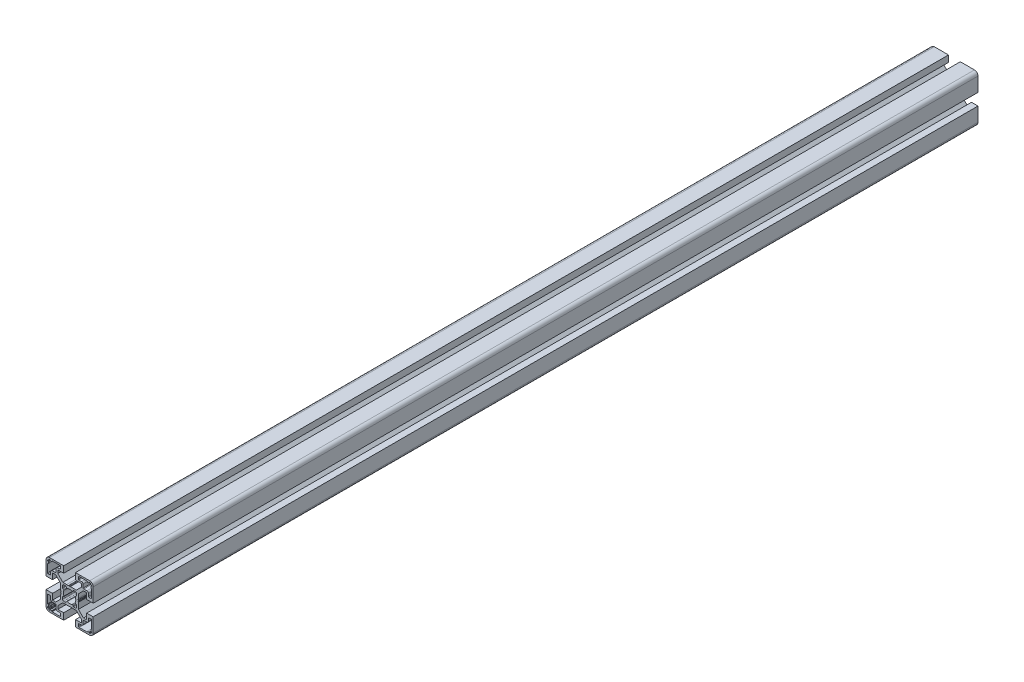
from build123d import *

# Parameters (mm, degrees)
BOSS_EXTRUDE1_DEPTH = 750


with BuildPart() as part:
    # Sketch1 → Boss-Extrude1 (new body)
    with BuildSketch(Plane.XY):
        with BuildLine():
            Line((-11.767766953, -10), (-14.5, -10))
            Line((-14.5, -10), (-14.5, -5))
            Line((-14.5, -5), (-20, -5))
            Line((-20, -5), (-20, -17))
            ThreePointArc((-20, -17), (-19.121320344, -19.121320344), (-17, -20))
            Line((-17, -20), (-5, -20))
            Line((-5, -20), (-5, -14.5))
            Line((-5, -14.5), (-10, -14.5))
            Line((-10, -14.5), (-10, -11.767766953))
            Line((-10, -11.767766953), (-5.732233047, -7.5))
            Line((-5.732233047, -7.5), (-0.653589838, -7.5))
            ThreePointArc((-0.653589838, -7.5), (-0.524180316, -7.482962913), (-0.403589838, -7.433012702))
            Line((-0.403589838, -7.433012702), (0, -7.2))
            Line((0, -7.2), (0.403589838, -7.433012702))
            ThreePointArc((0.403589838, -7.433012702), (0.653589838, -7.5), (0.903589838, -7.433012702))
            Line((0.903589838, -7.433012702), (1.218885629, -7.250976592))
            Line((1.218885629, -7.250976592), (2.5, -7.5))
            Line((2.5, -7.5), (5.732233047, -7.5))
            Line((5.732233047, -7.5), (10, -11.767766953))
            Line((10, -11.767766953), (10, -14.5))
            Line((10, -14.5), (5, -14.5))
            Line((5, -14.5), (5, -20))
            Line((5, -20), (17, -20))
            ThreePointArc((17, -20), (19.121320344, -19.121320344), (20, -17))
            Line((20, -17), (20, -5))
            Line((20, -5), (14.5, -5))
            Line((14.5, -5), (14.5, -10))
            Line((14.5, -10), (11.767766953, -10))
            Line((11.767766953, -10), (7.5, -5.732233047))
            Line((7.5, -5.732233047), (7.5, -0.653589838))
            ThreePointArc((7.5, -0.653589838), (7.482962913, -0.524180316), (7.433012702, -0.403589838))
            Line((7.433012702, -0.403589838), (7.2, 0))
            Line((7.2, 0), (7.433012702, 0.403589838))
            ThreePointArc((7.433012702, 0.403589838), (7.5, 0.653589838), (7.433012702, 0.903589838))
            Line((7.433012702, 0.903589838), (7.250976592, 1.218885629))
            Line((7.250976592, 1.218885629), (7.5, 2.5))
            Line((7.5, 2.5), (7.5, 5.732233047))
            Line((7.5, 5.732233047), (11.767766953, 10))
            Line((11.767766953, 10), (14.5, 10))
            Line((14.5, 10), (14.5, 5))
            Line((14.5, 5), (20, 5))
            Line((20, 5), (20, 17))
            ThreePointArc((20, 17), (19.121320344, 19.121320344), (17, 20))
            Line((17, 20), (5, 20))
            Line((5, 20), (5, 14.5))
            Line((5, 14.5), (10, 14.5))
            Line((10, 14.5), (10, 11.767766953))
            Line((10, 11.767766953), (5.732233047, 7.5))
            Line((5.732233047, 7.5), (0.653589838, 7.5))
            ThreePointArc((0.653589838, 7.5), (0.524180316, 7.482962913), (0.403589838, 7.433012702))
            Line((0.403589838, 7.433012702), (0, 7.2))
            Line((0, 7.2), (-0.403589838, 7.433012702))
            ThreePointArc((-0.403589838, 7.433012702), (-0.653589838, 7.5), (-0.903589838, 7.433012702))
            Line((-0.903589838, 7.433012702), (-1.218885629, 7.250976592))
            Line((-1.218885629, 7.250976592), (-2.5, 7.5))
            Line((-2.5, 7.5), (-5.732233047, 7.5))
            Line((-5.732233047, 7.5), (-10, 11.767766953))
            Line((-10, 11.767766953), (-10, 14.5))
            Line((-10, 14.5), (-5, 14.5))
            Line((-5, 14.5), (-5, 20))
            Line((-5, 20), (-17, 20))
            ThreePointArc((-17, 20), (-19.121320344, 19.121320344), (-20, 17))
            Line((-20, 17), (-20, 5))
            Line((-20, 5), (-14.5, 5))
            Line((-14.5, 5), (-14.5, 10))
            Line((-14.5, 10), (-11.767766953, 10))
            Line((-11.767766953, 10), (-7.5, 5.732233047))
            Line((-7.5, 5.732233047), (-7.5, 0.653589838))
            ThreePointArc((-7.5, 0.653589838), (-7.482962913, 0.524180316), (-7.433012702, 0.403589838))
            Line((-7.433012702, 0.403589838), (-7.2, 0))
            Line((-7.2, 0), (-7.433012702, -0.403589838))
            ThreePointArc((-7.433012702, -0.403589838), (-7.5, -0.653589838), (-7.433012702, -0.903589838))
            Line((-7.433012702, -0.903589838), (-7.250976592, -1.218885629))
            Line((-7.250976592, -1.218885629), (-7.5, -2.5))
            Line((-7.5, -2.5), (-7.5, -5.732233047))
            Line((-7.5, -5.732233047), (-11.767766953, -10))
        make_face()
        with BuildLine():
            Line((7.5, 16.5), (7.5, 18.2))
            ThreePointArc((7.5, 18.2), (7.646446609, 18.553553391), (8, 18.7))
            Line((8, 18.7), (14.8, 18.7))
            ThreePointArc((14.8, 18.7), (14.941421356, 18.641421356), (15, 18.5))
            Line((15, 18.5), (15, 18.2))
            ThreePointArc((15, 18.2), (15.058578644, 18.058578644), (15.2, 18))
            Line((15.2, 18), (16.4, 18))
            ThreePointArc((16.4, 18), (16.541421356, 18.058578644), (16.6, 18.2))
            Line((16.6, 18.2), (16.6, 18.5))
            ThreePointArc((16.6, 18.5), (16.658578644, 18.641421356), (16.8, 18.7))
            Line((16.8, 18.7), (17.3, 18.7))
            ThreePointArc((17.3, 18.7), (17.512132034, 18.612132034), (17.6, 18.4))
            Line((17.6, 18.4), (17.6, 17.9))
            ThreePointArc((17.6, 17.9), (17.687867966, 17.687867966), (17.9, 17.6))
            Line((17.9, 17.6), (18.4, 17.6))
            ThreePointArc((18.4, 17.6), (18.612132034, 17.512132034), (18.7, 17.3))
            Line((18.7, 17.3), (18.7, 16.8))
            ThreePointArc((18.7, 16.8), (18.641421356, 16.658578644), (18.5, 16.6))
            Line((18.5, 16.6), (18.2, 16.6))
            ThreePointArc((18.2, 16.6), (18.058578644, 16.541421356), (18, 16.4))
            Line((18, 16.4), (18, 15.2))
            ThreePointArc((18, 15.2), (18.058578644, 15.058578644), (18.2, 15))
            Line((18.2, 15), (18.5, 15))
            ThreePointArc((18.5, 15), (18.641421356, 14.941421356), (18.7, 14.8))
            Line((18.7, 14.8), (18.7, 8))
            ThreePointArc((18.7, 8), (18.553553391, 7.646446609), (18.2, 7.5))
            Line((18.2, 7.5), (16.5, 7.5))
            ThreePointArc((16.5, 7.5), (16.146446609, 7.646446609), (16, 8))
            Line((16, 8), (16, 10.2))
            ThreePointArc((16, 10.2), (15.619238816, 11.119238816), (14.7, 11.5))
            Line((14.7, 11.5), (12, 11.5))
            ThreePointArc((12, 11.5), (11.646446609, 11.646446609), (11.5, 12))
            Line((11.5, 12), (11.5, 14.7))
            ThreePointArc((11.5, 14.7), (11.119238816, 15.619238816), (10.2, 16))
            Line((10.2, 16), (8, 16))
            ThreePointArc((8, 16), (7.646446609, 16.146446609), (7.5, 16.5))
        make_face(mode=Mode.SUBTRACT)
        with BuildLine():
            Line((14.8, -18.7), (8, -18.7))
            ThreePointArc((8, -18.7), (7.646446609, -18.553553391), (7.5, -18.2))
            Line((7.5, -18.2), (7.5, -16.5))
            ThreePointArc((7.5, -16.5), (7.646446609, -16.146446609), (8, -16))
            Line((8, -16), (10.2, -16))
            ThreePointArc((10.2, -16), (11.119238816, -15.619238816), (11.5, -14.7))
            Line((11.5, -14.7), (11.5, -12))
            ThreePointArc((11.5, -12), (11.646446609, -11.646446609), (12, -11.5))
            Line((12, -11.5), (14.7, -11.5))
            ThreePointArc((14.7, -11.5), (15.619238816, -11.119238816), (16, -10.2))
            Line((16, -10.2), (16, -8))
            ThreePointArc((16, -8), (16.146446609, -7.646446609), (16.5, -7.5))
            Line((16.5, -7.5), (18.2, -7.5))
            ThreePointArc((18.2, -7.5), (18.553553391, -7.646446609), (18.7, -8))
            Line((18.7, -8), (18.7, -14.8))
            ThreePointArc((18.7, -14.8), (18.641421356, -14.941421356), (18.5, -15))
            Line((18.5, -15), (18.2, -15))
            ThreePointArc((18.2, -15), (18.058578644, -15.058578644), (18, -15.2))
            Line((18, -15.2), (18, -16.4))
            ThreePointArc((18, -16.4), (18.058578644, -16.541421356), (18.2, -16.6))
            Line((18.2, -16.6), (18.5, -16.6))
            ThreePointArc((18.5, -16.6), (18.641421356, -16.658578644), (18.7, -16.8))
            Line((18.7, -16.8), (18.7, -17.3))
            ThreePointArc((18.7, -17.3), (18.612132034, -17.512132034), (18.4, -17.6))
            Line((18.4, -17.6), (17.9, -17.6))
            ThreePointArc((17.9, -17.6), (17.687867966, -17.687867966), (17.6, -17.9))
            Line((17.6, -17.9), (17.6, -18.4))
            ThreePointArc((17.6, -18.4), (17.512132034, -18.612132034), (17.3, -18.7))
            Line((17.3, -18.7), (16.8, -18.7))
            ThreePointArc((16.8, -18.7), (16.658578644, -18.641421356), (16.6, -18.5))
            Line((16.6, -18.5), (16.6, -18.2))
            ThreePointArc((16.6, -18.2), (16.541421356, -18.058578644), (16.4, -18))
            Line((16.4, -18), (15.2, -18))
            ThreePointArc((15.2, -18), (15.058578644, -18.058578644), (15, -18.2))
            Line((15, -18.2), (15, -18.5))
            ThreePointArc((15, -18.5), (14.941421356, -18.641421356), (14.8, -18.7))
        make_face(mode=Mode.SUBTRACT)
        with BuildLine():
            Line((-18.7, 16.8), (-18.7, 17.3))
            ThreePointArc((-18.7, 17.3), (-18.612132034, 17.512132034), (-18.4, 17.6))
            Line((-18.4, 17.6), (-17.9, 17.6))
            ThreePointArc((-17.9, 17.6), (-17.687867966, 17.687867966), (-17.6, 17.9))
            Line((-17.6, 17.9), (-17.6, 18.4))
            ThreePointArc((-17.6, 18.4), (-17.512132034, 18.612132034), (-17.3, 18.7))
            Line((-17.3, 18.7), (-16.8, 18.7))
            ThreePointArc((-16.8, 18.7), (-16.658578644, 18.641421356), (-16.6, 18.5))
            Line((-16.6, 18.5), (-16.6, 18.2))
            ThreePointArc((-16.6, 18.2), (-16.541421356, 18.058578644), (-16.4, 18))
            Line((-16.4, 18), (-15.2, 18))
            ThreePointArc((-15.2, 18), (-15.058578644, 18.058578644), (-15, 18.2))
            Line((-15, 18.2), (-15, 18.5))
            ThreePointArc((-15, 18.5), (-14.941421356, 18.641421356), (-14.8, 18.7))
            Line((-14.8, 18.7), (-8, 18.7))
            ThreePointArc((-8, 18.7), (-7.646446609, 18.553553391), (-7.5, 18.2))
            Line((-7.5, 18.2), (-7.5, 16.5))
            ThreePointArc((-7.5, 16.5), (-7.646446609, 16.146446609), (-8, 16))
            Line((-8, 16), (-10.2, 16))
            ThreePointArc((-10.2, 16), (-11.119238816, 15.619238816), (-11.5, 14.7))
            Line((-11.5, 14.7), (-11.5, 12))
            ThreePointArc((-11.5, 12), (-11.646446609, 11.646446609), (-12, 11.5))
            Line((-12, 11.5), (-14.7, 11.5))
            ThreePointArc((-14.7, 11.5), (-15.619238816, 11.119238816), (-16, 10.2))
            Line((-16, 10.2), (-16, 8))
            ThreePointArc((-16, 8), (-16.146446609, 7.646446609), (-16.5, 7.5))
            Line((-16.5, 7.5), (-18.2, 7.5))
            ThreePointArc((-18.2, 7.5), (-18.553553391, 7.646446609), (-18.7, 8))
            Line((-18.7, 8), (-18.7, 14.8))
            ThreePointArc((-18.7, 14.8), (-18.641421356, 14.941421356), (-18.5, 15))
            Line((-18.5, 15), (-18.2, 15))
            ThreePointArc((-18.2, 15), (-18.058578644, 15.058578644), (-18, 15.2))
            Line((-18, 15.2), (-18, 16.4))
            ThreePointArc((-18, 16.4), (-18.058578644, 16.541421356), (-18.2, 16.6))
            Line((-18.2, 16.6), (-18.5, 16.6))
            ThreePointArc((-18.5, 16.6), (-18.641421356, 16.658578644), (-18.7, 16.8))
        make_face(mode=Mode.SUBTRACT)
        with BuildLine():
            Line((-18.7, -14.8), (-18.7, -8))
            ThreePointArc((-18.7, -8), (-18.553553391, -7.646446609), (-18.2, -7.5))
            Line((-18.2, -7.5), (-16.5, -7.5))
            ThreePointArc((-16.5, -7.5), (-16.146446609, -7.646446609), (-16, -8))
            Line((-16, -8), (-16, -10.2))
            ThreePointArc((-16, -10.2), (-15.619238816, -11.119238816), (-14.7, -11.5))
            Line((-14.7, -11.5), (-12, -11.5))
            ThreePointArc((-12, -11.5), (-11.646446609, -11.646446609), (-11.5, -12))
            Line((-11.5, -12), (-11.5, -14.7))
            ThreePointArc((-11.5, -14.7), (-11.119238816, -15.619238816), (-10.2, -16))
            Line((-10.2, -16), (-8, -16))
            ThreePointArc((-8, -16), (-7.646446609, -16.146446609), (-7.5, -16.5))
            Line((-7.5, -16.5), (-7.5, -18.2))
            ThreePointArc((-7.5, -18.2), (-7.646446609, -18.553553391), (-8, -18.7))
            Line((-8, -18.7), (-14.8, -18.7))
            ThreePointArc((-14.8, -18.7), (-14.941421356, -18.641421356), (-15, -18.5))
            Line((-15, -18.5), (-15, -18.2))
            ThreePointArc((-15, -18.2), (-15.058578644, -18.058578644), (-15.2, -18))
            Line((-15.2, -18), (-16.4, -18))
            ThreePointArc((-16.4, -18), (-16.541421356, -18.058578644), (-16.6, -18.2))
            Line((-16.6, -18.2), (-16.6, -18.5))
            ThreePointArc((-16.6, -18.5), (-16.658578644, -18.641421356), (-16.8, -18.7))
            Line((-16.8, -18.7), (-17.3, -18.7))
            ThreePointArc((-17.3, -18.7), (-17.512132034, -18.612132034), (-17.6, -18.4))
            Line((-17.6, -18.4), (-17.6, -17.9))
            ThreePointArc((-17.6, -17.9), (-17.687867966, -17.687867966), (-17.9, -17.6))
            Line((-17.9, -17.6), (-18.4, -17.6))
            ThreePointArc((-18.4, -17.6), (-18.612132034, -17.512132034), (-18.7, -17.3))
            Line((-18.7, -17.3), (-18.7, -16.8))
            ThreePointArc((-18.7, -16.8), (-18.641421356, -16.658578644), (-18.5, -16.6))
            Line((-18.5, -16.6), (-18.2, -16.6))
            ThreePointArc((-18.2, -16.6), (-18.058578644, -16.541421356), (-18, -16.4))
            Line((-18, -16.4), (-18, -15.2))
            ThreePointArc((-18, -15.2), (-18.058578644, -15.058578644), (-18.2, -15))
            Line((-18.2, -15), (-18.5, -15))
            ThreePointArc((-18.5, -15), (-18.641421356, -14.941421356), (-18.7, -14.8))
        make_face(mode=Mode.SUBTRACT)
        with BuildLine():
            Line((-6, 3.490686899), (-6, 5))
            ThreePointArc((-6, 5), (-5.707106781, 5.707106781), (-5, 6))
            Line((-5, 6), (-3.490686899, 6))
            ThreePointArc((-3.490686899, 6), (-3.233167862, 5.92858365), (-3.049213103, 5.734735781))
            Line((-3.049213103, 5.734735781), (-2.689236216, 5.057717724))
            ThreePointArc((-2.689236216, 5.057717724), (-2.414618721, 4.821116073), (-2.052304818, 4.832240157))
            ThreePointArc((-2.052304818, 4.832240157), (0, 5.25), (2.052304818, 4.832240157))
            ThreePointArc((2.052304818, 4.832240157), (2.414618721, 4.821116073), (2.689236216, 5.057717724))
            Line((2.689236216, 5.057717724), (3.049213103, 5.734735781))
            ThreePointArc((3.049213103, 5.734735781), (3.233167862, 5.92858365), (3.490686899, 6))
            Line((3.490686899, 6), (5, 6))
            ThreePointArc((5, 6), (5.707106781, 5.707106781), (6, 5))
            Line((6, 5), (6, 3.490686899))
            ThreePointArc((6, 3.490686899), (5.92858365, 3.233167862), (5.734735781, 3.049213103))
            Line((5.734735781, 3.049213103), (5.057717724, 2.689236216))
            ThreePointArc((5.057717724, 2.689236216), (4.821116073, 2.414618721), (4.832240157, 2.052304818))
            ThreePointArc((4.832240157, 2.052304818), (5.25, 0), (4.832240157, -2.052304818))
            ThreePointArc((4.832240157, -2.052304818), (4.821116073, -2.414618721), (5.057717724, -2.689236216))
            Line((5.057717724, -2.689236216), (5.734735781, -3.049213103))
            ThreePointArc((5.734735781, -3.049213103), (5.92858365, -3.233167862), (6, -3.490686899))
            Line((6, -3.490686899), (6, -5))
            ThreePointArc((6, -5), (5.707106781, -5.707106781), (5, -6))
            Line((5, -6), (3.490686899, -6))
            ThreePointArc((3.490686899, -6), (3.233167862, -5.92858365), (3.049213103, -5.734735781))
            Line((3.049213103, -5.734735781), (2.689236216, -5.057717724))
            ThreePointArc((2.689236216, -5.057717724), (2.414618721, -4.821116073), (2.052304818, -4.832240157))
            ThreePointArc((2.052304818, -4.832240157), (0, -5.25), (-2.052304818, -4.832240157))
            ThreePointArc((-2.052304818, -4.832240157), (-2.414618721, -4.821116073), (-2.689236216, -5.057717724))
            Line((-2.689236216, -5.057717724), (-3.049213103, -5.734735781))
            ThreePointArc((-3.049213103, -5.734735781), (-3.233167862, -5.92858365), (-3.490686899, -6))
            Line((-3.490686899, -6), (-5, -6))
            ThreePointArc((-5, -6), (-5.707106781, -5.707106781), (-6, -5))
            Line((-6, -5), (-6, -3.490686899))
            ThreePointArc((-6, -3.490686899), (-5.92858365, -3.233167862), (-5.734735781, -3.049213103))
            Line((-5.734735781, -3.049213103), (-5.057717724, -2.689236216))
            ThreePointArc((-5.057717724, -2.689236216), (-4.821116073, -2.414618721), (-4.832240157, -2.052304818))
            ThreePointArc((-4.832240157, -2.052304818), (-5.25, 0), (-4.832240157, 2.052304818))
            ThreePointArc((-4.832240157, 2.052304818), (-4.821116073, 2.414618721), (-5.057717724, 2.689236216))
            Line((-5.057717724, 2.689236216), (-5.734735781, 3.049213103))
            ThreePointArc((-5.734735781, 3.049213103), (-5.92858365, 3.233167862), (-6, 3.490686899))
        make_face(mode=Mode.SUBTRACT)
    extrude(amount=-BOSS_EXTRUDE1_DEPTH)


solid = part.part
